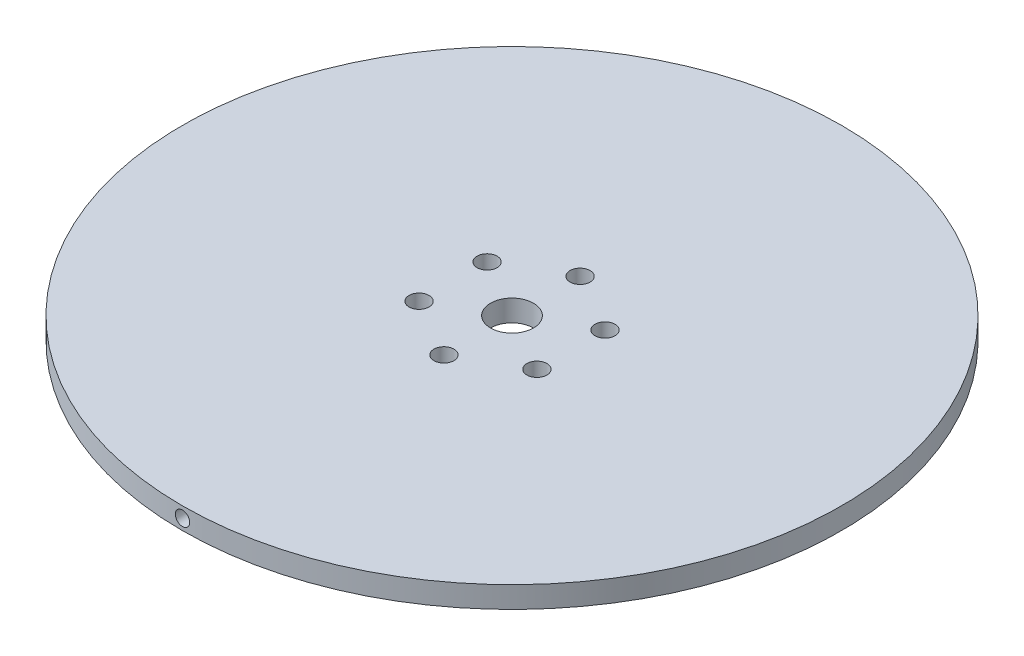
from build123d import *

# Parameters (mm, degrees)
SKETCH1_R           = 46
SKETCH1_R_2         = 3
SKETCH1_R_3         = 1.4
BOSS_EXTRUDE1_DEPTH = 3
SKETCH5_R           = 1
CUT_EXTRUDE1_DEPTH  = 3
SKETCH6_R           = 1
CUT_EXTRUDE2_DEPTH  = 3


with BuildPart() as part:
    # Sketch1 → Boss-Extrude1 (new body)
    with BuildSketch(Plane(origin=(0, 0, 0), x_dir=(1, 0, 0), z_dir=(0, 1, 0))):
        Circle(SKETCH1_R)
        Circle(SKETCH1_R_2, mode=Mode.SUBTRACT)
        with Locations((0, 9.5)):
            Circle(SKETCH1_R_3, mode=Mode.SUBTRACT)
        with Locations((8.227241336, 4.75)):
            Circle(SKETCH1_R_3, mode=Mode.SUBTRACT)
        with Locations((8.227241336, -4.75)):
            Circle(SKETCH1_R_3, mode=Mode.SUBTRACT)
        with Locations((0, -9.5)):
            Circle(SKETCH1_R_3, mode=Mode.SUBTRACT)
        with Locations((-8.227241336, -4.75)):
            Circle(SKETCH1_R_3, mode=Mode.SUBTRACT)
        with Locations((-8.227241336, 4.75)):
            Circle(SKETCH1_R_3, mode=Mode.SUBTRACT)
    extrude(amount=BOSS_EXTRUDE1_DEPTH)

    # Sketch5 → Cut-Extrude1 (cut)
    with BuildSketch(Plane.XY.offset(46)):
        with Locations((0, 1.5)):
            Circle(SKETCH5_R)
    extrude(amount=-CUT_EXTRUDE1_DEPTH, mode=Mode.SUBTRACT)

    # Sketch6 → Cut-Extrude2 (cut)
    with BuildSketch(Plane.XY.offset(-46)):
        with Locations((0, 1.5)):
            Circle(SKETCH6_R)
    extrude(amount=CUT_EXTRUDE2_DEPTH, mode=Mode.SUBTRACT)


solid = part.part
